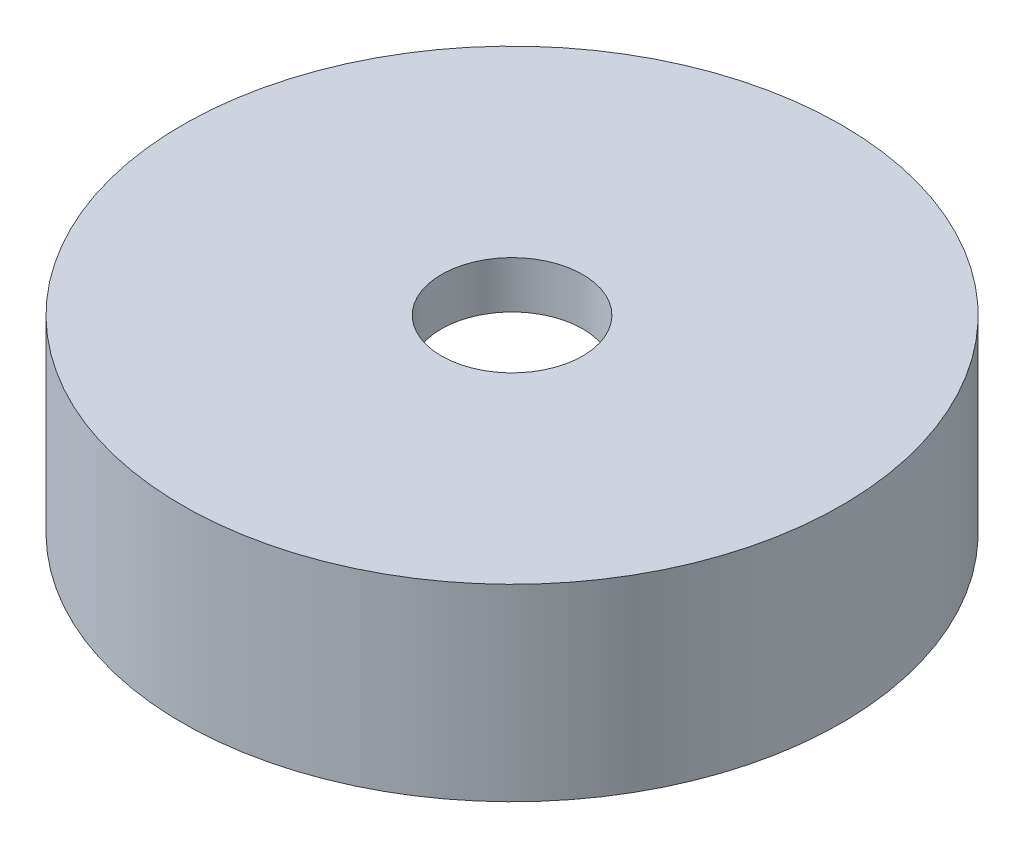
from build123d import *

# Parameters (mm, degrees)
F_3_0MM_DOWEL_HOLE1_D     = 3
F_3_0MM_DOWEL_HOLE1_DEPTH = 7.598709071
F_3_0MM_DOWEL_HOLE1_TIP   = 0.901290929


with BuildPart() as part:
    # Sketch1 → Revolve1 (revolve)
    with BuildSketch(Plane.XY):
        Polygon((0, 3), (6, 3), (6, 0), (7, 0), (7, 4), (0, 4), align=None)
    revolve(axis=Axis((0, 0, 0), (0, 1, 0)))

    # Ø3.0mm Dowel Hole1
    with Locations(Plane(origin=(0, 4, 0), x_dir=(1, 0, 0), z_dir=(0, 1, 0))):
        with Locations((0, 0)):
            Hole(F_3_0MM_DOWEL_HOLE1_D / 2, depth=F_3_0MM_DOWEL_HOLE1_DEPTH)
            with Locations((0, 0, -(F_3_0MM_DOWEL_HOLE1_DEPTH + F_3_0MM_DOWEL_HOLE1_TIP / 2))):  # 118° drill point
                Cone(0, F_3_0MM_DOWEL_HOLE1_D / 2, F_3_0MM_DOWEL_HOLE1_TIP, mode=Mode.SUBTRACT)


solid = part.part
